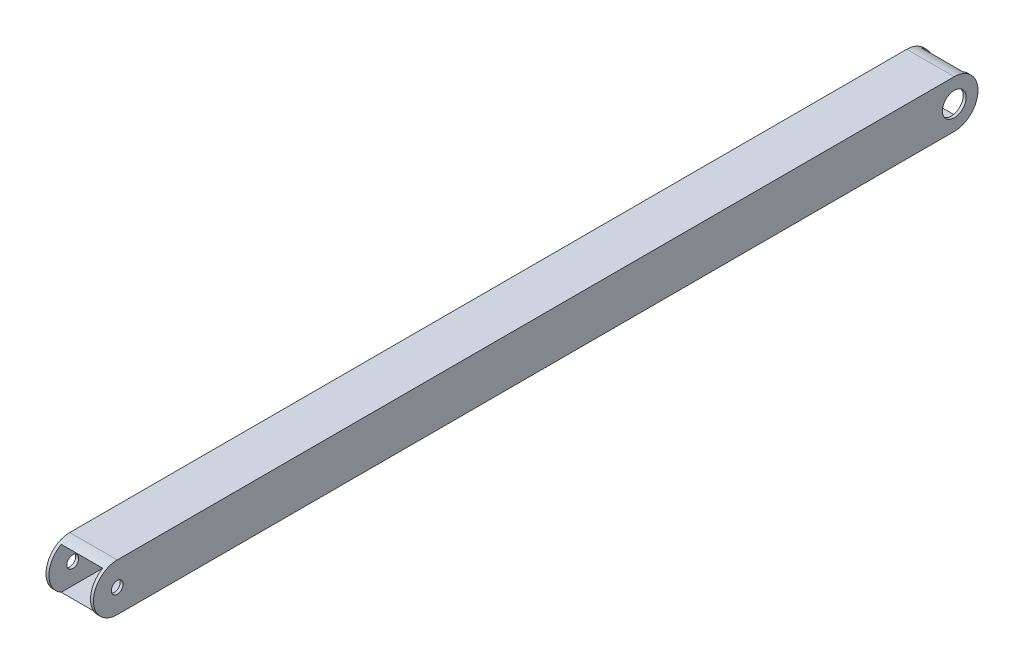
from build123d import *

# Parameters (mm, degrees)
SKETCH1_W           = 25.4
SKETCH1_H           = 25.4
SKETCH1_W_2         = 22.225
SKETCH1_H_2         = 22.225
BOSS_EXTRUDE1_DEPTH = 473.2274
CUT_EXTRUDE1_DEPTH  = 26.4
SKETCH3_R           = 3.175
SKETCH3_R_2         = 6.35
CUT_EXTRUDE2_DEPTH  = 26.4
CUT_EXTRUDE3_DEPTH  = 26.4


with BuildPart() as part:
    # Sketch1 → Boss-Extrude1 (new body)
    with BuildSketch(Plane.XY):
        Rectangle(SKETCH1_W, SKETCH1_H)
        Rectangle(SKETCH1_W_2, SKETCH1_H_2, mode=Mode.SUBTRACT)
    extrude(amount=BOSS_EXTRUDE1_DEPTH)

    # Sketch2 → Cut-Extrude1 (cut, through all)
    with BuildSketch(Plane(origin=(12.7, 0, 0), x_dir=(0, 0, -1), z_dir=(1, 0, 0))):
        with BuildLine():
            Line((-460.5274, 12.7), (-473.2274, 12.7))
            Line((-473.2274, 12.7), (-473.2274, 9.7e-08))
            ThreePointArc((-473.2274, 9.7e-08), (-469.507656087, 8.980256155), (-460.5274, 12.7))
        make_face()
        with BuildLine():
            ThreePointArc((-460.5274, -12.7), (-469.507656155, -8.980256087), (-473.2274, 9.7e-08))
            Line((-473.2274, 9.7e-08), (-473.2274, -12.7))
            Line((-473.2274, -12.7), (-460.5274, -12.7))
        make_face()
    extrude(amount=-CUT_EXTRUDE1_DEPTH, mode=Mode.SUBTRACT)

    # Sketch3 → Cut-Extrude2 (cut, through all)
    with BuildSketch(Plane(origin=(12.7, 0, 0), x_dir=(0, 0, -1), z_dir=(1, 0, 0))):
        with Locations((-460.5274, 0)):
            Circle(SKETCH3_R)
        with Locations((-12.7, 0)):
            Circle(SKETCH3_R_2)
    extrude(amount=-CUT_EXTRUDE2_DEPTH, mode=Mode.SUBTRACT)

    # Sketch5 → Cut-Extrude3 (cut, through all)
    with BuildSketch(Plane(origin=(12.7, 0, 0), x_dir=(0, 0, -1), z_dir=(1, 0, 0))):
        with BuildLine():
            Line((0, 12.7), (-12.7, 12.7))
            ThreePointArc((-12.7, 12.7), (-3.719743879, 8.980256121), (0, 0))
            Line((0, 0), (0, 12.7))
        make_face()
        with BuildLine():
            Line((0, -12.7), (0, 0))
            ThreePointArc((0, 0), (-3.719743879, -8.980256121), (-12.7, -12.7))
            Line((-12.7, -12.7), (0, -12.7))
        make_face()
    extrude(amount=-CUT_EXTRUDE3_DEPTH, mode=Mode.SUBTRACT)


solid = part.part
